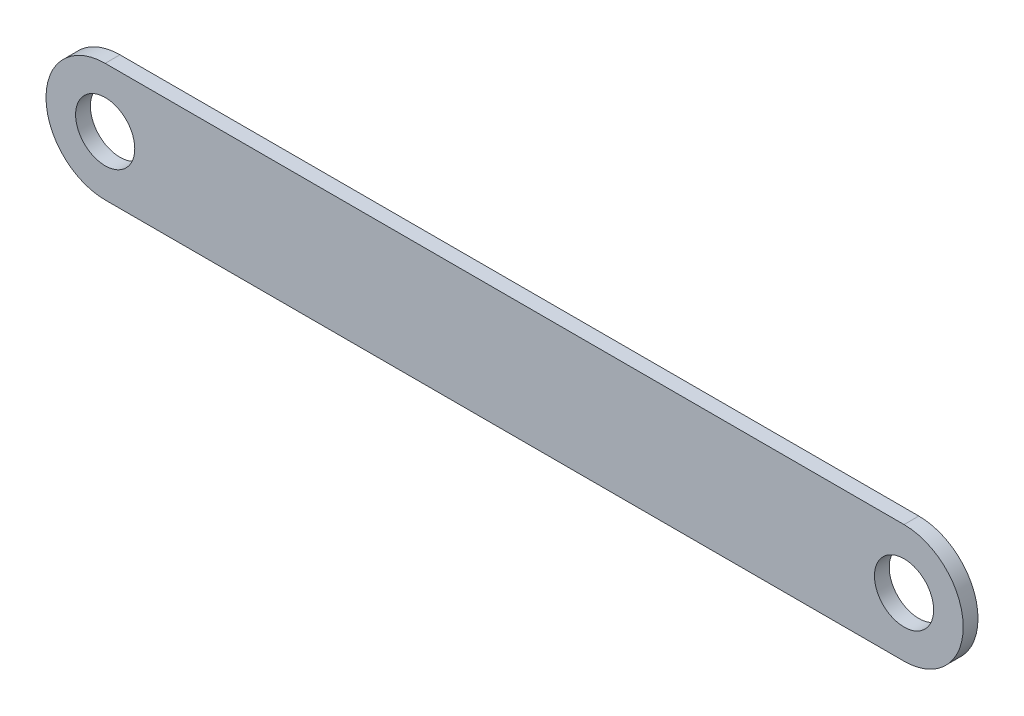
from build123d import *

# Parameters (mm, degrees)
EXTRUDE1_DEPTH     = 5
SKETCH2_R          = 10
CUT_EXTRUDE1_DEPTH = 6


with BuildPart() as part:
    # Sketch1 → Extrude1 (new body)
    with BuildSketch(Plane.XY):
        with BuildLine():
            Line((51.513050076, 21.557056146), (-218.486949924, 21.557056146))
            ThreePointArc((-218.486949924, 21.557056146), (-238.486949924, 1.557056146), (-218.486949924, -18.442943854))
            Line((-218.486949924, -18.442943854), (51.513050076, -18.442943854))
            ThreePointArc((51.513050076, -18.442943854), (71.513050076, 1.557056146), (51.513050076, 21.557056146))
        make_face()
    extrude(amount=EXTRUDE1_DEPTH)

    # Sketch2 → Cut-Extrude1 (cut, through all)
    with BuildSketch(Plane.XY.offset(5)):
        with Locations((-218.486949924, 1.557056146)):
            Circle(SKETCH2_R)
        with Locations((51.513050076, 1.557056146)):
            Circle(SKETCH2_R)
    extrude(amount=-CUT_EXTRUDE1_DEPTH, mode=Mode.SUBTRACT)


solid = part.part
